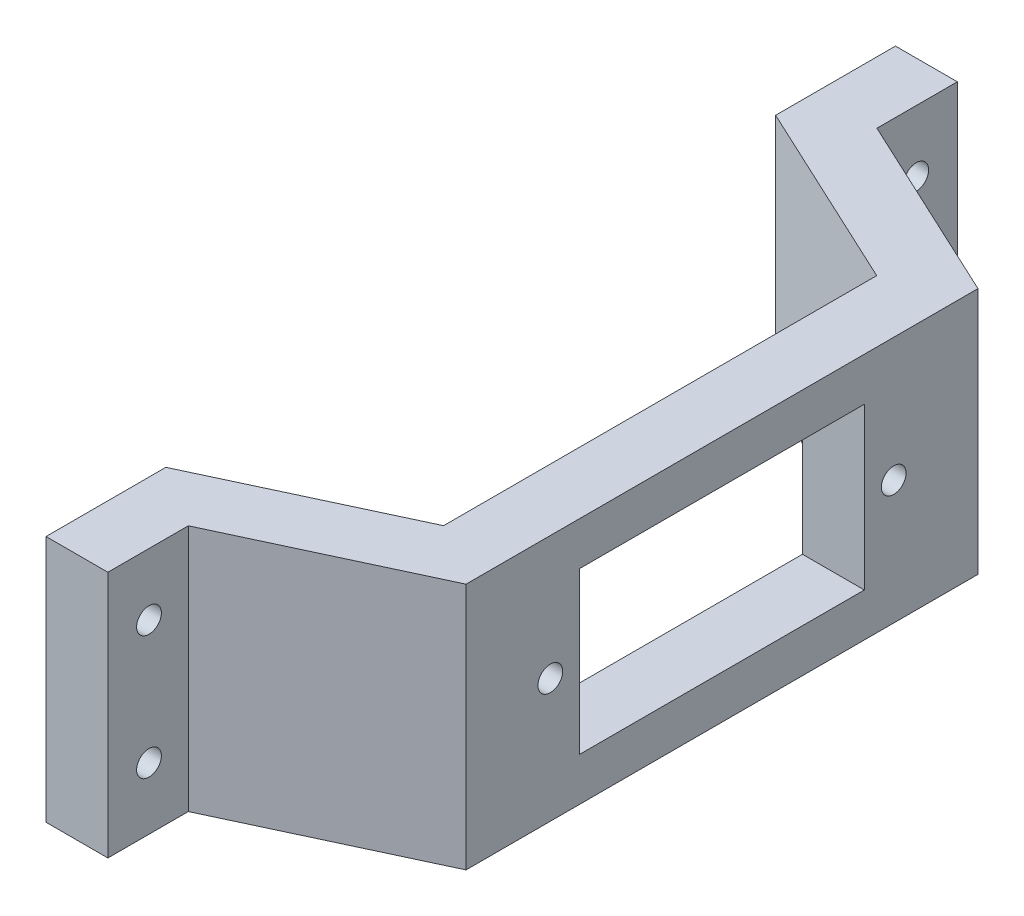
from build123d import *

# Parameters (mm, degrees)
BOSS_EXTRUDE1_DEPTH      = 10
BOSS_EXTRUDE1_DEPTH_BACK = 10
SKETCH3_R                = 1
SKETCH3_W                = 23
SKETCH3_H                = 13
CUT_EXTRUDE1_DEPTH       = 39.889503993
SKETCH5_R                = 1
CUT_EXTRUDE2_DEPTH       = 39.889503993


with BuildPart() as part:
    # Sketch1 → Boss-Extrude1 (new, two sides: drawn at the far end of the back side and taken through both)
    with BuildSketch(Plane(origin=(0, 0, 0), x_dir=(1, 0, 0), z_dir=(0, 1, 0)).offset(-BOSS_EXTRUDE1_DEPTH_BACK)):
        Polygon((0, 34.323215889), (0, 24.637864585), (15.3072, 17.5), (15.3072, -17.5), (0, -24.637864585), (0, -34.323215889), (5, -34.323215889), (5, -27.823215889), (20.3072, -20.685351304), (20.3072, 20.685351304), (5, 27.823215889), (5, 34.323215889), align=None)
    extrude(amount=BOSS_EXTRUDE1_DEPTH + BOSS_EXTRUDE1_DEPTH_BACK)

    # Sketch3 → Cut-Extrude1 (cut, through all)
    with BuildSketch(Plane.ZY.offset(-15.3072)):
        with Locations((-13.875, 0)):
            Circle(SKETCH3_R)
        with Locations((13.875, 0)):
            Circle(SKETCH3_R)
        Rectangle(SKETCH3_W, SKETCH3_H)
    extrude(amount=-CUT_EXTRUDE1_DEPTH, mode=Mode.SUBTRACT)

    # Sketch5 → Cut-Extrude2 (cut, through all)
    with BuildSketch(Plane(origin=(5, 0, 0), x_dir=(0, 0, -1), z_dir=(1, 0, 0))):
        with Locations((31, -5)):
            Circle(SKETCH5_R)
        with Locations((31, 5)):
            Circle(SKETCH5_R)
        with Locations((-31, 5)):
            Circle(SKETCH5_R)
        with Locations((-31, -5)):
            Circle(SKETCH5_R)
    extrude(amount=-CUT_EXTRUDE2_DEPTH, mode=Mode.SUBTRACT)


solid = part.part
